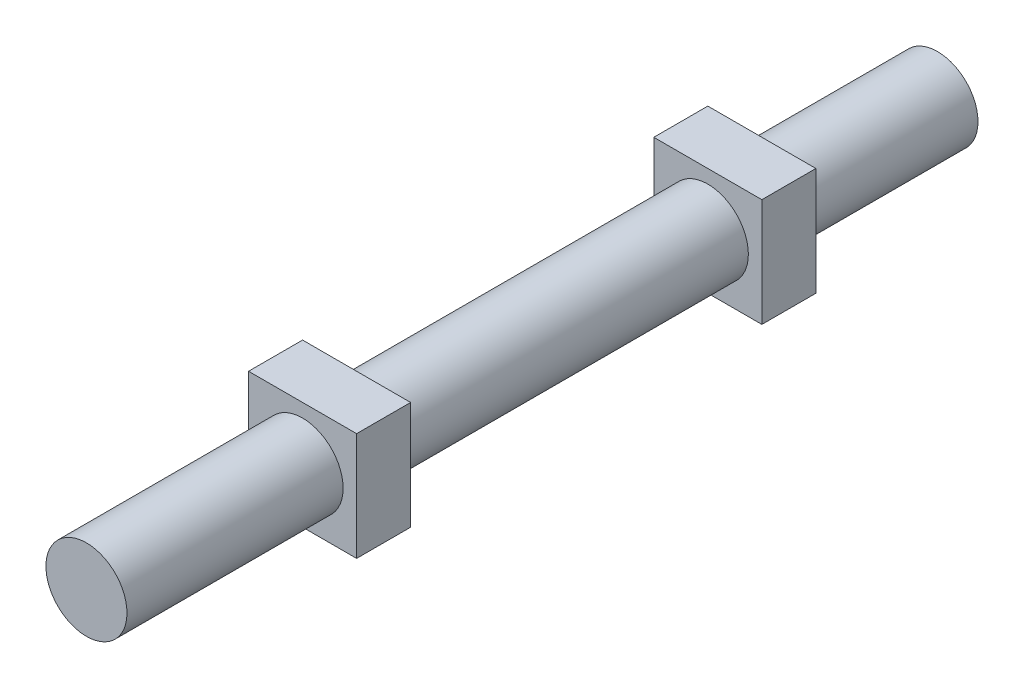
from build123d import *

# Parameters (mm, degrees)
SKETCH1_R           = 7.5
BOSS_EXTRUDE1_DEPTH = 157.5
SKETCH2_W           = 20
SKETCH2_H           = 20
BOSS_EXTRUDE2_DEPTH = 10
SKETCH3_W           = 20
SKETCH3_H           = 20
BOSS_EXTRUDE3_DEPTH = 10


with BuildPart() as part:
    # Sketch1 → Boss-Extrude1 (new body)
    with BuildSketch(Plane.XY):
        Circle(SKETCH1_R)
    extrude(amount=BOSS_EXTRUDE1_DEPTH)

    # Sketch2 → Boss-Extrude2 (add)
    with BuildSketch(Plane.XY.offset(107.5)):
        Rectangle(SKETCH2_W, SKETCH2_H)
    extrude(amount=BOSS_EXTRUDE2_DEPTH)

    # Sketch3 → Boss-Extrude3 (add)
    with BuildSketch(Plane.XY.offset(32.5)):
        Rectangle(SKETCH3_W, SKETCH3_H)
    extrude(amount=BOSS_EXTRUDE3_DEPTH)


solid = part.part
